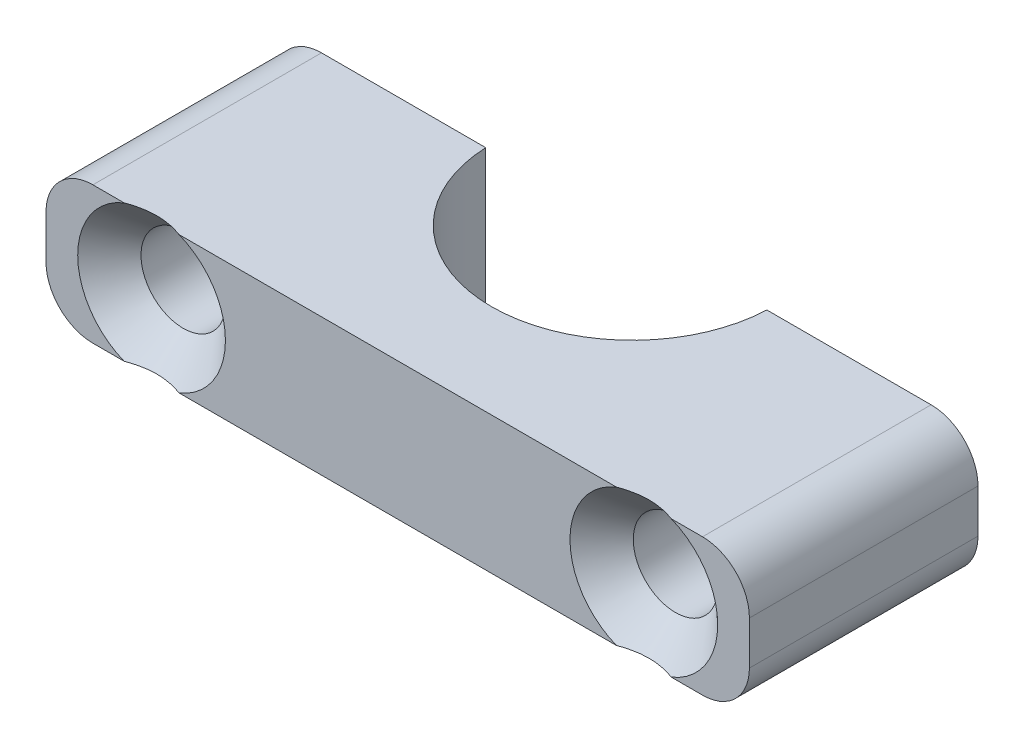
from build123d import *

# Parameters (mm, degrees)
BOSS_EXTRUDE1_DEPTH                             = 2.925
CSK_FOR_M3_FLAT_HEAD_MACHINE_SCREW1_D           = 3.6
CSK_FOR_M3_FLAT_HEAD_MACHINE_SCREW1_CSINK_D     = 6.3
CSK_FOR_M3_FLAT_HEAD_MACHINE_SCREW1_CSINK_ANGLE = 90
FILLET1_R                                       = 2


with BuildPart() as part:
    # Sketch2 → Boss-Extrude1 (new body, symmetric)
    with BuildSketch(Plane(origin=(0, 0, 0), x_dir=(1, 0, 0), z_dir=(0, 1, 0))):
        with BuildLine():
            Line((-15, -4.875), (15, -4.875))
            Line((15, -4.875), (15, 4.875))
            Line((15, 4.875), (5.994789404, 4.875))
            ThreePointArc((5.994789404, 4.875), (0, -0.875), (-5.994789404, 4.875))
            Line((-5.994789404, 4.875), (-15, 4.875))
            Line((-15, 4.875), (-15, -4.875))
        make_face()
    extrude(amount=BOSS_EXTRUDE1_DEPTH, both=True)

    # CSK for M3 Flat Head Machine Screw1 (through all)
    with Locations(Plane.XY.offset(4.875)):
        with Locations((-10.497394702, 0), (10.497394702, 0)):
            CounterSinkHole(CSK_FOR_M3_FLAT_HEAD_MACHINE_SCREW1_D / 2, CSK_FOR_M3_FLAT_HEAD_MACHINE_SCREW1_CSINK_D / 2, counter_sink_angle=CSK_FOR_M3_FLAT_HEAD_MACHINE_SCREW1_CSINK_ANGLE)

    # Fillet1
    fillet1_edges = [part.edges().sort_by_distance(p)[0] for p in [
        (-15, 2.925, 0),
        (15, 2.925, 0),
        (15, -2.925, 0),
        (-15, -2.925, 0),
    ]]
    fillet(fillet1_edges, radius=FILLET1_R)


solid = part.part
